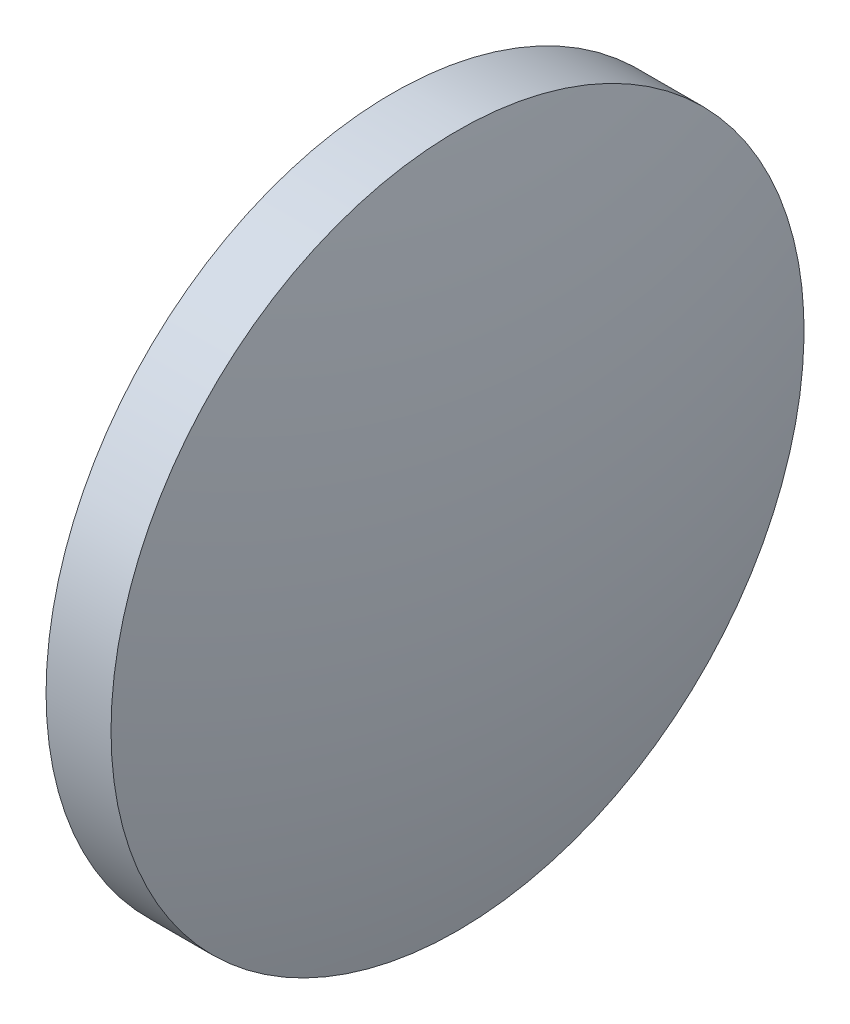
from build123d import *


with BuildPart() as part:
    # 草图2 → 旋转2 (revolve)
    with BuildSketch(Plane.XY, mode=Mode.PRIVATE) as revolve_2_sk:
        with BuildLine():
            Line((524.160297715, 67.777086322), (524.160297715, 75.777086322))
            Line((524.160297715, 75.777086322), (525.660297715, 75.777086322))
            ThreePointArc((525.660297715, 75.777086322), (526.409328708, 71.808215197), (526.660297715, 67.777086322))
            Line((526.660297715, 67.777086322), (524.160297715, 67.777086322))
        make_face()
    revolve(revolve_2_sk.sketch.rotate(Axis((522.23748101, 67.777086322, 0), (1, 0, 0)), 180), axis=Axis((522.23748101, 67.777086322, 0), (1, 0, 0)))  # turned: the seam where the file's is


solid = part.part
